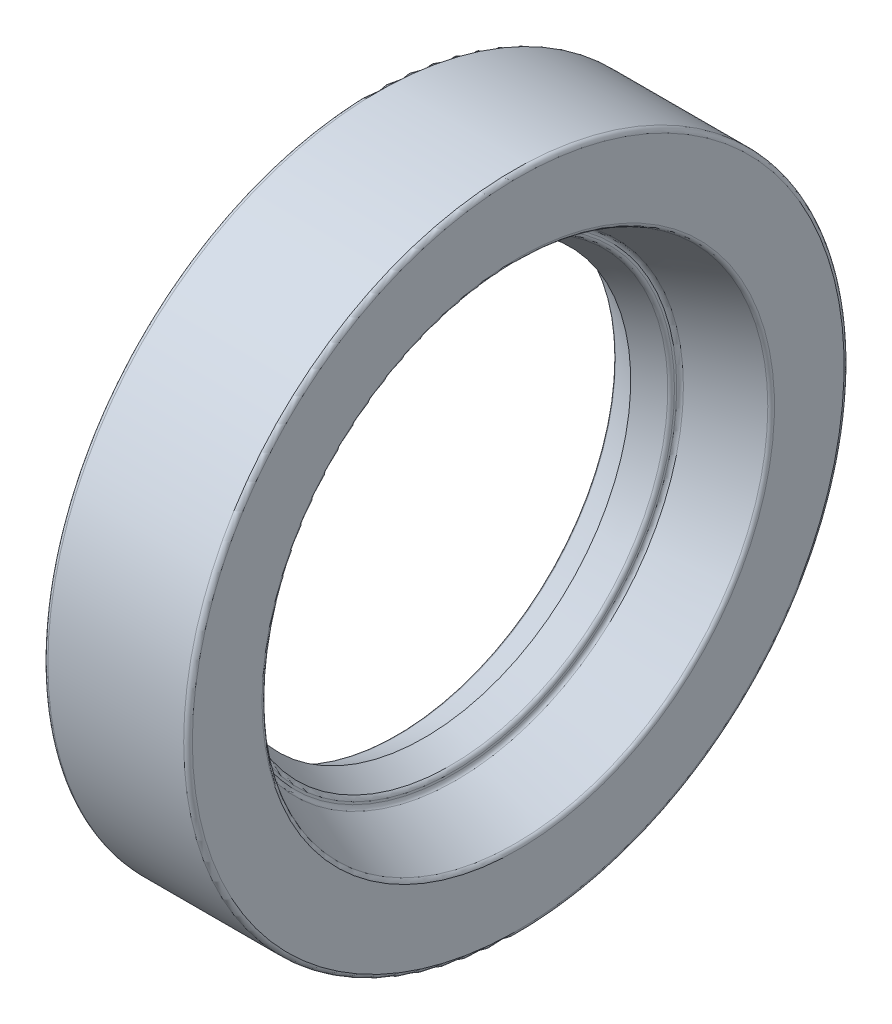
from build123d import *

# Parameters (mm, degrees)
ZAOBLIT1_R = 0.21
SKICA2_R   = 0.525
SKICA2_R_2 = 0.42551639
SKICA2_R_3 = 0.105


with BuildPart() as part:
    # Skica1 → Otočit kolem osy1 (revolve)
    with BuildSketch(Plane.XY):
        with BuildLine():
            Line((-2.45, 16), (4.55, 16))
            Line((4.55, 16), (4.55, 12.275))
            Line((4.55, 12.275), (1.4, 10.970227279))
            Line((1.4, 10.970227279), (1.4, 10.579898987))
            Line((1.4, 10.579898987), (0, 10))
            Line((0, 10), (-1.4, 10.579898987))
            Line((-1.4, 10.579898987), (-1.4, 11.75))
            Line((-1.4, 11.75), (-0.525, 11.75))
            ThreePointArc((-0.525, 11.75), (0, 11.225), (0.525, 11.75))
            Line((0.525, 11.75), (1.965522411, 11.75))
            Line((1.965522411, 11.75), (3.5, 12.385601428))
            Line((3.5, 12.385601428), (3.5, 14.952221422))
            Line((3.5, 14.952221422), (-2.45, 15.16))
            Line((-2.45, 15.16), (-2.45, 16))
        make_face()
    revolve(axis=Axis((0, 0, 0), (1, 0, 0)))

    # Zaoblit1
    zaoblit1_edges = [part.edges().sort_by_distance(p)[0] for p in [
        (-1.4, -10.579898987, 0),
        (-1.4, -11.75, 0),
        (1.965522411, -11.75, 0),
        (3.5, -12.385601428, 0),
        (3.5, -14.952221422, 0),
        (-2.45, -15.16, 0),
        (-2.45, -16, 0),
        (4.55, -16, 0),
        (4.55, -12.275, 0),
        (1.4, -10.970227279, 0),
        (1.4, -10.579898987, 0),
    ]]
    fillet(zaoblit1_edges, radius=ZAOBLIT1_R)


with BuildPart() as body_2:
    # Skica2 → Otočit kolem osy3 (revolve)
    with BuildSketch(Plane(origin=(0, 0, 0), x_dir=(1, 0, 0), z_dir=(0, 1, 0))):
        with Locations((0, 11.75)):
            Circle(SKICA2_R)
        with Locations((0, 11.75)):
            Circle(SKICA2_R_2, mode=Mode.SUBTRACT)
        with Locations((0, 11.75)):
            Circle(SKICA2_R_3)
    revolve(axis=Axis((0, 0, 0), (1, 0, 0)))


solid = Compound([part.part, body_2.part])
